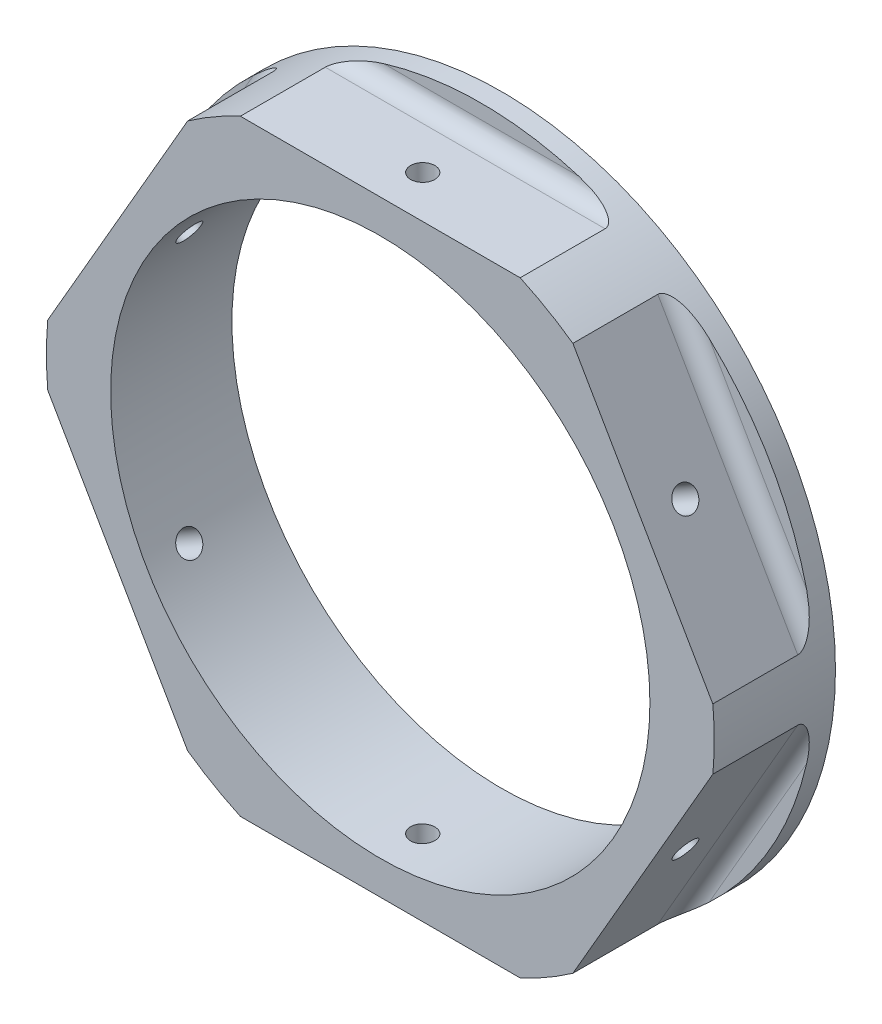
from build123d import *

# Parameters (mm, degrees)
SZKIC2_R                    = 46.017617149
DODANIE_WYCI_GNI_CIE1_DEPTH = 2.5
DODANIE_WYCI_GNI_CIE2_DEPTH = 15
SZKIC3_R                    = 46.5
SZKIC3_R_2                  = 42.5
WYTNIJ_WYCI_GNI_CIE3_DEPTH  = 10
SZKIC8_R                    = 33.35
WYTNIJ_WYCI_GNI_CIE2_DEPTH  = 62.947558467
ZAOKR_GLENIE2_R             = 2
SZKIC9_R                    = 1.5
WYTNIJ_WYCI_GNI_CIE4_DEPTH  = 10
SZYK_KO_OWY1_COUNT          = 6
SZKIC10_R                   = 50
SZKIC10_R_2                 = 41.3
WYTNIJ_WYCI_GNI_CIE5_DEPTH  = 62.947558491


with BuildPart() as part:
    # Szkic2 → Dodanie-wyci_gni_cie1 (new body)
    with BuildSketch(Plane.XY):
        Circle(SZKIC2_R)
    extrude(amount=DODANIE_WYCI_GNI_CIE1_DEPTH)

    # Szkic2_3 → Dodanie-wyci_gni_cie2 (add)
    with BuildSketch(Plane.XY):
        with BuildLine():
            ThreePointArc((17.776388835, -37.5), (20.75, -35.940054257), (23.587758225, -34.144804318))
            Line((23.587758225, -34.144804318), (41.364147059, -3.355195682))
            ThreePointArc((41.364147059, -3.355195682), (41.466022856, -1.67897246), (41.5, 0))
            ThreePointArc((41.5, 0), (41.466022856, 1.67897246), (41.364147059, 3.355195682))
            Line((41.364147059, 3.355195682), (23.587758225, 34.144804318))
            ThreePointArc((23.587758225, 34.144804318), (20.75, 35.940054257), (17.776388835, 37.5))
            Line((17.776388835, 37.5), (-17.776388835, 37.5))
            ThreePointArc((-17.776388835, 37.5), (-20.75, 35.940054257), (-23.587758225, 34.144804318))
            Line((-23.587758225, 34.144804318), (-41.364147059, 3.355195682))
            ThreePointArc((-41.364147059, 3.355195682), (-41.5, 0), (-41.364147059, -3.355195682))
            Line((-41.364147059, -3.355195682), (-23.587758225, -34.144804318))
            ThreePointArc((-23.587758225, -34.144804318), (-20.75, -35.940054257), (-17.776388835, -37.5))
            Line((-17.776388835, -37.5), (17.776388835, -37.5))
        make_face()
    extrude(amount=DODANIE_WYCI_GNI_CIE2_DEPTH)

    # Szkic3 → Wytnij-wyci_gni_cie3 (cut)
    with BuildSketch(Plane(origin=(0, 0, 2.5), x_dir=(-1, 0, 0), z_dir=(0, 0, -1))):
        Circle(SZKIC3_R)
        Circle(SZKIC3_R_2, mode=Mode.SUBTRACT)
    extrude(amount=WYTNIJ_WYCI_GNI_CIE3_DEPTH, mode=Mode.SUBTRACT)

    # Szkic8 → Wytnij-wyci_gni_cie2 (cut, through all)
    with BuildSketch(Plane.XY.offset(15)):
        Circle(SZKIC8_R)
    extrude(amount=-WYTNIJ_WYCI_GNI_CIE2_DEPTH, mode=Mode.SUBTRACT)

    # Zaokr_glenie2
    zaokr_glenie2_edges = [part.edges().sort_by_distance(p)[0] for p in [
        (-32.475952642, 18.75, 2.5),
        (0, 37.5, 2.5),
        (32.475952642, 18.75, 2.5),
        (32.475952642, -18.75, 2.5),
        (0, -37.5, 2.5),
        (-32.475952642, -18.75, 2.5),
    ]]
    fillet(zaokr_glenie2_edges, radius=ZAOKR_GLENIE2_R)

    # Szkic9 → Wytnij-wyci_gni_cie4 (cut)
    with BuildSketch(Plane(origin=(-32.475952642, -18.75, 0), x_dir=(0, 0, 1), z_dir=(-0.8660254037844386, -0.5000000000000001, 0))):
        with Locations((9.75, 0)):
            Circle(SZKIC9_R)
    wytnij_wyci_gni_cie4 = extrude(amount=-WYTNIJ_WYCI_GNI_CIE4_DEPTH, mode=Mode.SUBTRACT)

    # Szyk ko_owy1: Wytnij-wyci_gni_cie4 ×6 about axis
    szyk_ko_owy1_axis = Axis((0, 0, 15), (0, 0, -1))
    for i in range(1, SZYK_KO_OWY1_COUNT):
        add(wytnij_wyci_gni_cie4.rotate(szyk_ko_owy1_axis, i * 360 / SZYK_KO_OWY1_COUNT), mode=Mode.SUBTRACT)

    # Szkic10 → Wytnij-wyci_gni_cie5 (cut, through all)
    with BuildSketch(Plane.XY.offset(15)):
        Circle(SZKIC10_R)
        Circle(SZKIC10_R_2, mode=Mode.SUBTRACT)
    extrude(amount=-WYTNIJ_WYCI_GNI_CIE5_DEPTH, mode=Mode.SUBTRACT)


solid = part.part
